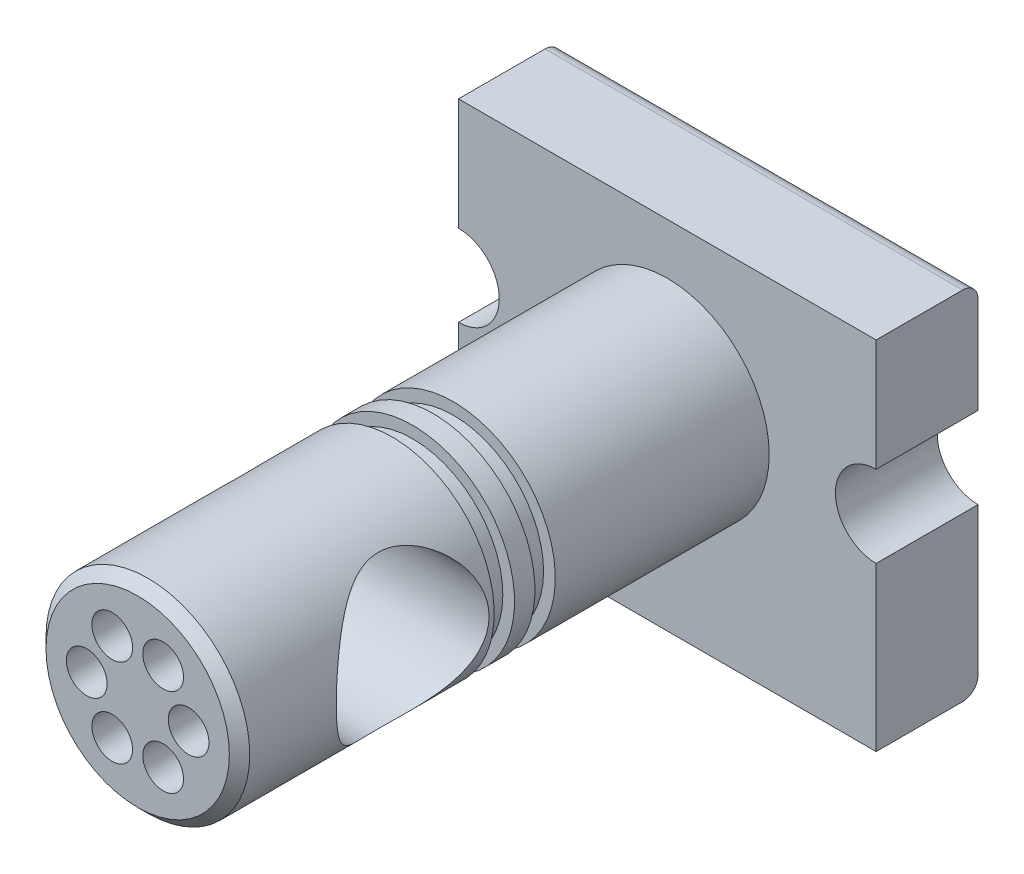
from build123d import *

# Parameters (mm, degrees)
SKETCH1_W               = 82
SKETCH1_H               = 70
BOSS_EXTRUDE1_DEPTH     = 20
SKETCH2_R               = 8
CUT_EXTRUDE1_DEPTH      = 20
SKETCH3_R               = 20
BOSS_EXTRUDE2_DEPTH     = 104
SKETCH4_R               = 15
CUT_EXTRUDE2_DEPTH      = 42
CUT_EXTRUDE2_DEPTH_BACK = 42
SKETCH5_W               = 2.3
SKETCH5_H               = 4
SKETCH6_R               = 4
CUT_EXTRUDE3_DEPTH      = 30
CIRPATTERN1_COUNT       = 6
CHAMFER1_SIZE           = 2
FILLET1_R               = 3


with BuildPart() as part:
    # Sketch1 → Boss-Extrude1 (new body)
    with BuildSketch(Plane.XY):
        with Locations((0, -5)):
            Rectangle(SKETCH1_W, SKETCH1_H)
    extrude(amount=BOSS_EXTRUDE1_DEPTH)

    # Sketch2 → Cut-Extrude1 (cut)
    with BuildSketch(Plane.XY.offset(20)):
        with Locations((-41, 0)):
            Circle(SKETCH2_R)
        with Locations((41, 0)):
            Circle(SKETCH2_R)
    extrude(amount=-CUT_EXTRUDE1_DEPTH, mode=Mode.SUBTRACT)

    # Sketch3 → Boss-Extrude2 (add)
    with BuildSketch(Plane.XY.offset(20)):
        Circle(SKETCH3_R)
    extrude(amount=BOSS_EXTRUDE2_DEPTH)

    # Sketch4 → Cut-Extrude2 (cut, two sides)
    with BuildSketch(Plane(origin=(0, 0, 0), x_dir=(0, 0, -1), z_dir=(1, 0, 0))) as cut_extrude2_sk:
        with Locations((-90, 0)):
            Circle(SKETCH4_R)
    extrude(amount=CUT_EXTRUDE2_DEPTH, mode=Mode.SUBTRACT)
    extrude(cut_extrude2_sk.sketch, amount=-CUT_EXTRUDE2_DEPTH_BACK, mode=Mode.SUBTRACT)

    # Sketch5 → Cut-Revolve1 (revolve, cut)
    with BuildSketch(Plane(origin=(0, 0, 0), x_dir=(1, 0, 0), z_dir=(0, 1, 0))):
        with Locations((18.85, -72)):
            Rectangle(SKETCH5_W, SKETCH5_H)
        with Locations((18.85, -64)):
            Rectangle(SKETCH5_W, SKETCH5_H)
    revolve(axis=Axis((0, 0, 20), (0, 0, 1)), mode=Mode.SUBTRACT)

    # Sketch6 → Cut-Extrude3 (cut)
    with BuildSketch(Plane.XY.offset(124)):
        with Locations((-10, 0)):
            Circle(SKETCH6_R)
    cut_extrude3 = extrude(amount=-CUT_EXTRUDE3_DEPTH, mode=Mode.SUBTRACT)

    # CirPattern1: Cut-Extrude3 ×6 about axis
    cirpattern1_axis = Axis((0, 0, 0), (0, 0, 1))
    for i in range(1, CIRPATTERN1_COUNT):
        add(cut_extrude3.rotate(cirpattern1_axis, i * 360 / CIRPATTERN1_COUNT), mode=Mode.SUBTRACT)

    # Chamfer1
    chamfer1_edges = [part.edges().sort_by_distance(p)[0] for p in [
        (-20, 0, 124),
    ]]
    chamfer(chamfer1_edges, length=CHAMFER1_SIZE)

    # Fillet1
    fillet1_edges = [part.edges().sort_by_distance(p)[0] for p in [
        (0, -40, 0),
        (0, 30, 0),
    ]]
    fillet(fillet1_edges, radius=FILLET1_R)


solid = part.part
